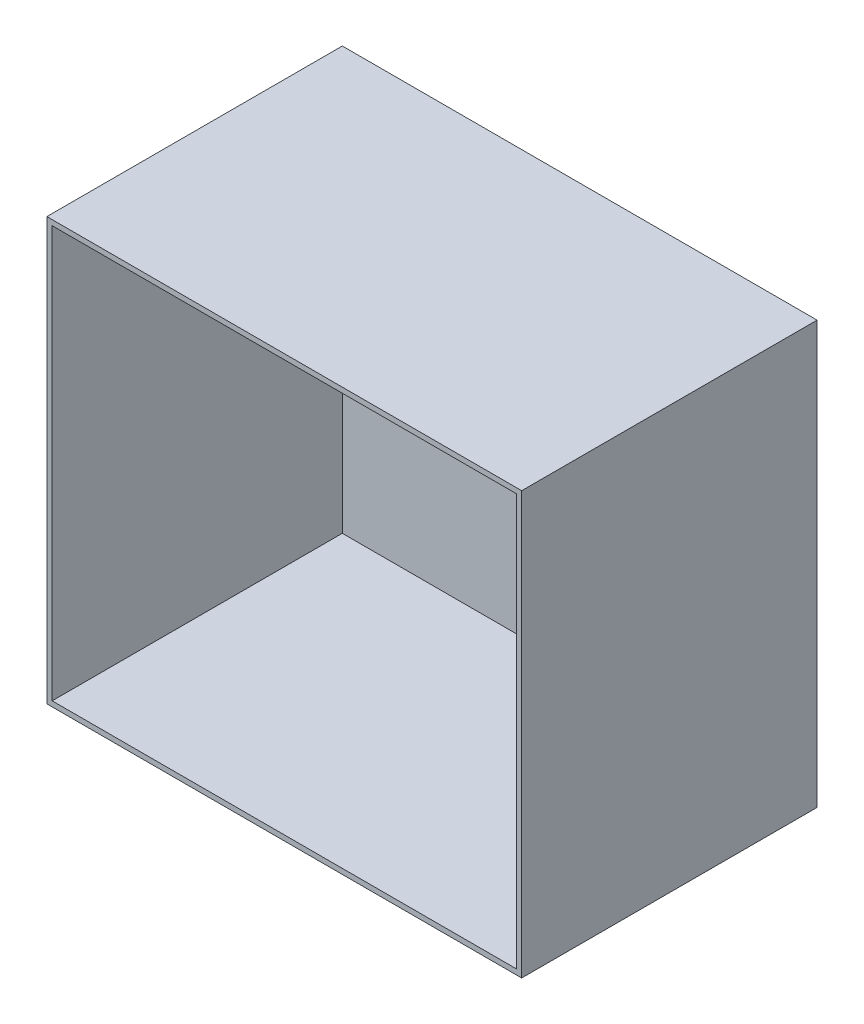
from build123d import *

# Parameters (mm, degrees)
SKETCH2_W           = 160
SKETCH2_H           = 160
BOSS_EXTRUDE1_DEPTH = 2
SKETCH4_W           = 2
SKETCH4_H           = 160
BOSS_EXTRUDE3_DEPTH = 20
SKETCH5_W           = 180
SKETCH5_H           = 160
SKETCH5_W_2         = 176
SKETCH5_H_2         = 156
BOSS_EXTRUDE5_DEPTH = 100
SKETCH6_W           = 180
SKETCH6_H           = 160
SKETCH6_W_2         = 176
SKETCH6_H_2         = 156
BOSS_EXTRUDE6_DEPTH = 10


with BuildPart() as part:
    # Sketch2 → Boss-Extrude1 (new body)
    with BuildSketch(Plane.XY):
        Rectangle(SKETCH2_W, SKETCH2_H)
    extrude(amount=BOSS_EXTRUDE1_DEPTH)

    # Sketch4 → Boss-Extrude3 (add)
    with BuildSketch(Plane(origin=(80, 0, 0), x_dir=(0, 0, -1), z_dir=(1, 0, 0))):
        with Locations((-1, 0)):
            Rectangle(SKETCH4_W, SKETCH4_H)
    extrude(amount=BOSS_EXTRUDE3_DEPTH)

    # Sketch5 → Boss-Extrude5 (add)
    with BuildSketch(Plane.XY.offset(2)):
        with Locations((10, 0)):
            Rectangle(SKETCH5_W, SKETCH5_H)
        with Locations((10, 0)):
            Rectangle(SKETCH5_W_2, SKETCH5_H_2, mode=Mode.SUBTRACT)
    extrude(amount=BOSS_EXTRUDE5_DEPTH)

    # Sketch6 → Boss-Extrude6 (add)
    with BuildSketch(Plane.XY.offset(102)):
        with Locations((10, 0)):
            Rectangle(SKETCH6_W, SKETCH6_H)
        with Locations((10, 0)):
            Rectangle(SKETCH6_W_2, SKETCH6_H_2, mode=Mode.SUBTRACT)
    extrude(amount=BOSS_EXTRUDE6_DEPTH)


solid = part.part
